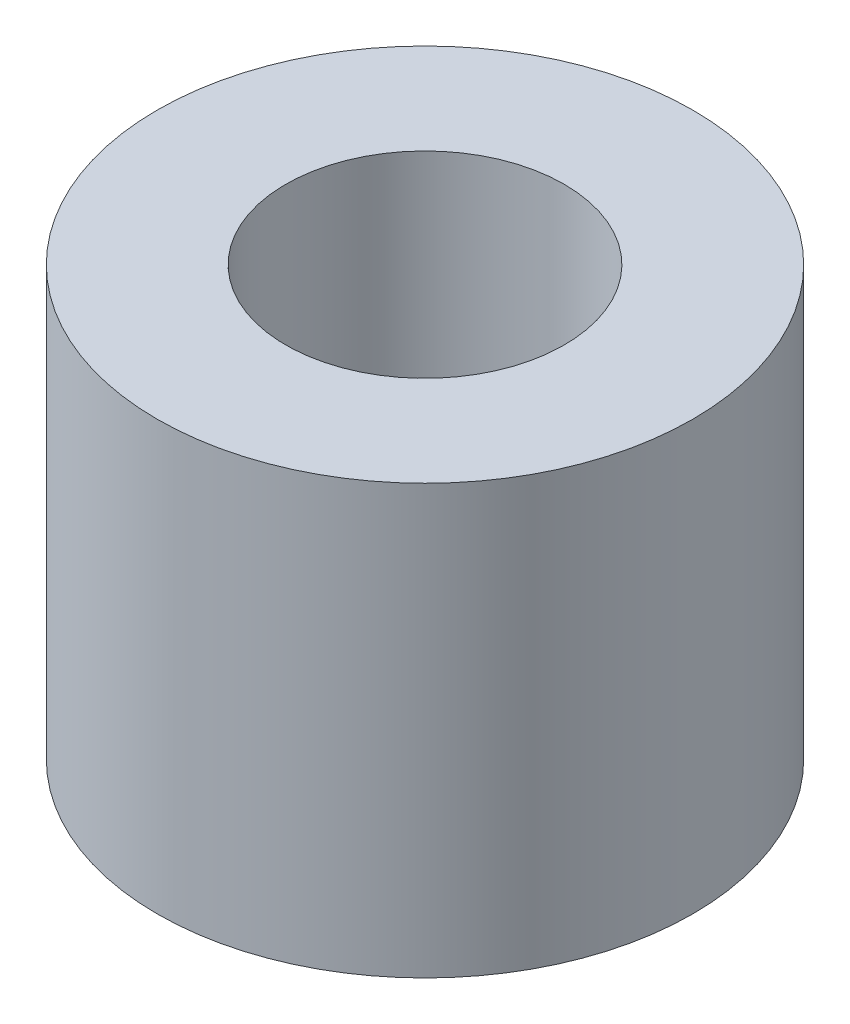
from build123d import *

# Parameters (mm, degrees)
SKETCH1_W = 2.4
SKETCH1_H = 8


with BuildPart() as part:
    # Sketch1 → Revolve1 (revolve)
    with BuildSketch(Plane.XY):
        with Locations((3.8, 4)):
            Rectangle(SKETCH1_W, SKETCH1_H)
    revolve(axis=Axis((0, 8, 0), (0, -1, 0)))


solid = part.part
